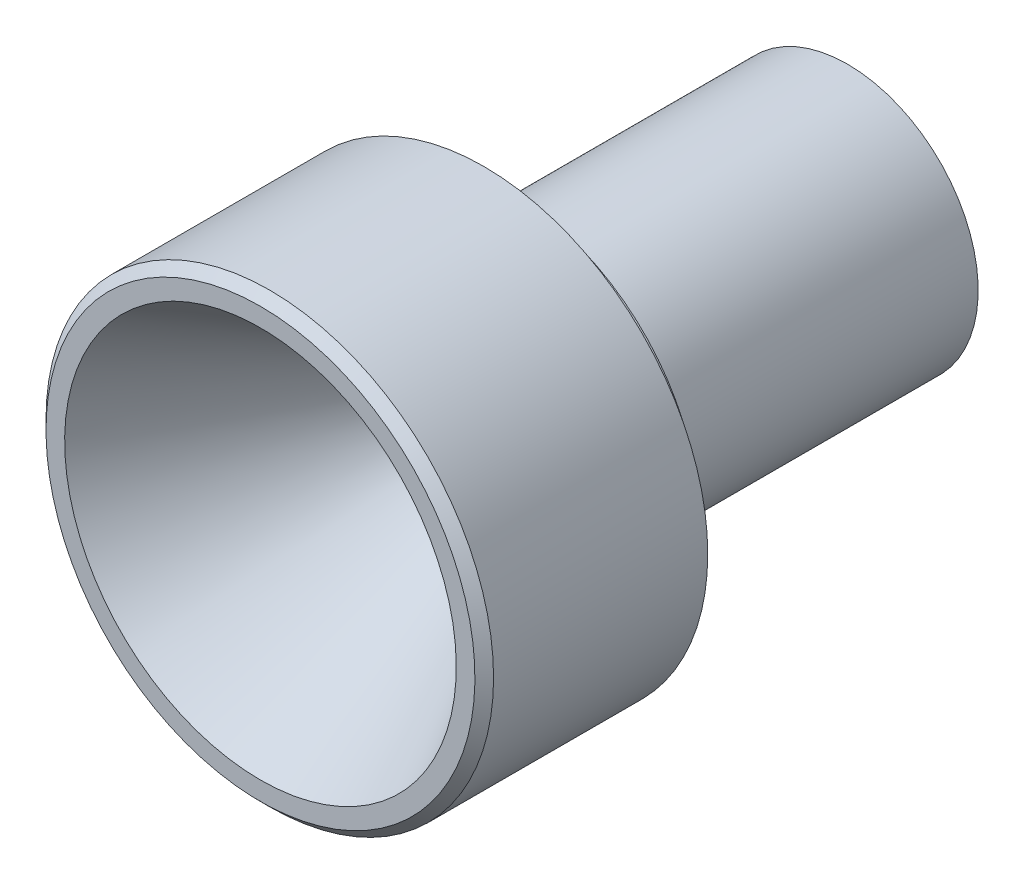
from build123d import *

# Parameters (mm, degrees)
CHANFREIN1_SIZE = 0.5


with BuildPart() as part:
    # Esquisse1 → Révolution1 (revolve)
    with BuildSketch(Plane(origin=(0, 0, 0), x_dir=(0, 0, -1), z_dir=(1, 0, 0))):
        Polygon((15.742003569, 4.5), (3.980428295, 2), (-1.019571705, 2), (-15.742003569, 10.5), (-15.742003569, 12), (-3.757996431, 12), (-3.757996431, 10), (-2.257996431, 10), (-2.257996431, 7), (15.742003569, 7), align=None)
    revolve(axis=Axis((0, 0, 15.742003569), (0, 0, -1)))

    # Chanfrein1
    chanfrein1_edges = [part.edges().sort_by_distance(p)[0] for p in [
        (0, -12, 15.742003569),
    ]]
    chamfer(chanfrein1_edges, length=CHANFREIN1_SIZE)


solid = part.part
